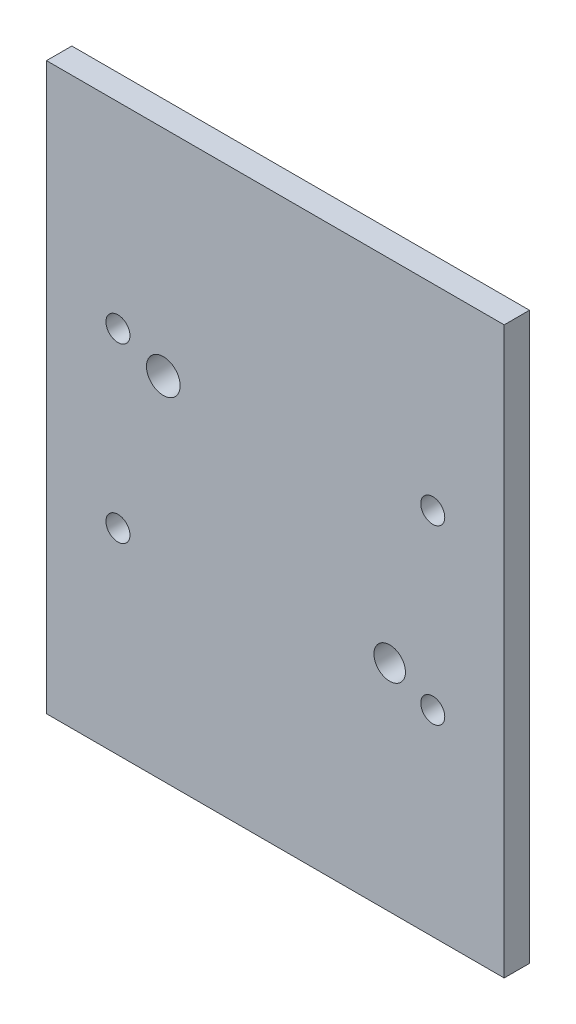
from build123d import *

# Parameters (mm, degrees)
SKETCH1_W             = 43.053
SKETCH1_H             = 53.213
BOSS_EXTRUDE1_DEPTH   = 2.38125
F_4_40_TAPPED_HOLE1_D = 2.2606
SKETCH5_R             = 1.583220457
SKETCH5_R_2           = 1.481870985
CUT_EXTRUDE1_DEPTH    = 3.38125


with BuildPart() as part:
    # Sketch1 → Boss-Extrude1 (new body)
    with BuildSketch(Plane.XY):
        with Locations((0, -26.6065)):
            Rectangle(SKETCH1_W, SKETCH1_H)
    extrude(amount=BOSS_EXTRUDE1_DEPTH)

    # #4-40 Tapped Hole1 (through all)
    with Locations(Plane.XY.offset(2.38125)):
        with Locations((-14.8082, -18.4804304), (14.8082, -18.4804304), (-14.8082, -34.7325696), (14.8082, -34.7325696)):
            Hole(F_4_40_TAPPED_HOLE1_D / 2)

    # Sketch5 → Cut-Extrude1 (cut, through all)
    with BuildSketch(Plane.XY.offset(2.38125)):
        with Locations((-10.538552378, -20.202865742)):
            Circle(SKETCH5_R)
        with Locations((10.758105553, -32.936949866)):
            Circle(SKETCH5_R_2)
    extrude(amount=-CUT_EXTRUDE1_DEPTH, mode=Mode.SUBTRACT)


solid = part.part
